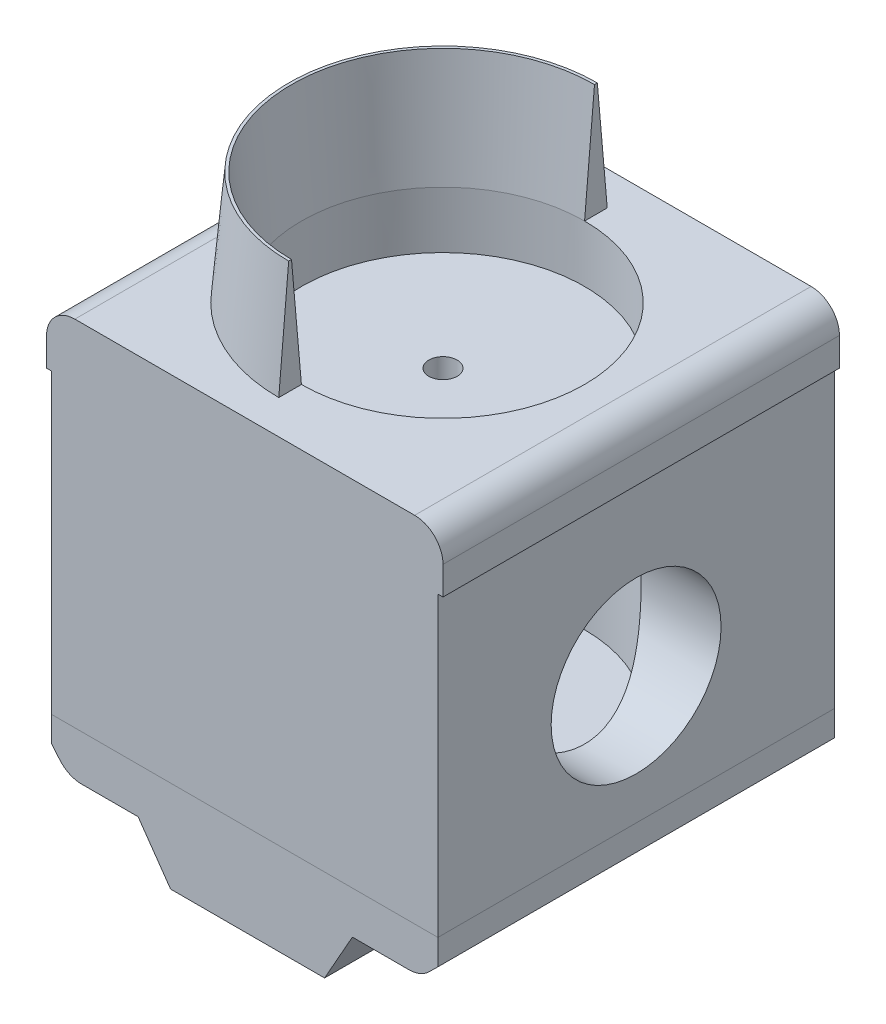
from build123d import *

# Parameters (mm, degrees)
BOSS_EXTRUDE1_DEPTH    = 70
SKETCH4_R              = 29
SKETCH4_R_2            = 25
EXTRUDE_THIN1_DEPTH    = 20
EXTRUDE_THIN1_DRAFT    = 5
SKETCH5_W              = 30
SKETCH5_H              = 70
CUT_EXTRUDE1_DEPTH     = 20
SKETCH7_R              = 25
CUT_EXTRUDE2_DEPTH     = 10
CUT_EXTRUDE3_START     = -68.710206
SKETCH8_R              = 2.5
CUT_EXTRUDE3_DEPTH     = 60.512739
SKETCH10_R             = 15
CUT_EXTRUDE4_DEPTH     = 30
SPLIT3_SURFACE_1_BACK  = 140.799
SPLIT3_SURFACE_1_DEPTH = 281.598
SPLIT3_SURFACE_2_BACK  = 140.799
SPLIT3_SURFACE_2_DEPTH = 281.598
SKETCH14_R             = 1.9
CUT_EXTRUDE5_DEPTH     = 20
SKETCH17_R             = 1.9
CUT_EXTRUDE7_DEPTH     = 20
CUT_EXTRUDE8_START     = -52.5
SKETCH19_R             = 25
CUT_EXTRUDE8_DEPTH     = 42.5


with BuildPart() as part:
    # Sketch1 → Boss-Extrude1 (new body)
    with BuildSketch(Plane.XY):
        with BuildLine():
            ThreePointArc((-1.711084805, -46.340962164), (-3.831514412, -45.869071955), (-5.551700031, -44.542473477))
            Line((-5.551700031, -44.542473477), (-6.980687822, -42.828223009))
            Line((-6.980687822, -42.828223009), (-6.980687822, 14.171776991))
            Line((-6.980687822, 14.171776991), (-7.881398643, 14.171776991))
            Line((-7.881398643, 14.171776991), (-7.881398643, 19.171776991))
            ThreePointArc((-7.881398643, 19.171776991), (-6.416932549, 22.707310897), (-2.881398643, 24.171776991))
            Line((-2.881398643, 24.171776991), (57.118601357, 24.171776991))
            ThreePointArc((57.118601357, 24.171776991), (60.654135263, 22.707310897), (62.118601357, 19.171776991))
            Line((62.118601357, 19.171776991), (62.118601357, 14.171776991))
            Line((62.118601357, 14.171776991), (61.217890536, 14.171776991))
            Line((61.217890536, 14.171776991), (61.217890536, -42.828223009))
            Line((61.217890536, -42.828223009), (59.626717013, -44.393096038))
            ThreePointArc((59.626717013, -44.393096038), (58.014921228, -45.45555297), (56.120767742, -45.828223009))
            Line((56.120767742, -45.828223009), (46.120767742, -45.828223009))
            Line((46.120767742, -45.828223009), (41.208302807, -54.538428992))
            Line((41.208302807, -54.538428992), (14.016177857, -54.538428992))
            Line((14.016177857, -54.538428992), (8.288915195, -46.340962164))
            Line((8.288915195, -46.340962164), (-1.711084805, -46.340962164))
        make_face()
    extrude(amount=BOSS_EXTRUDE1_DEPTH)


with BuildPart() as extrude_thin1_tool:
    # Sketch4 → Extrude-Thin1 (with draft: the straight prism first)
    with BuildSketch(Plane(origin=(0, 24.171776991, 0), x_dir=(1, 0, 0), z_dir=(0, 1, 0))):
        with Locations((27.118601357, -35)):
            Circle(SKETCH4_R)
        with Locations((27.118601357, -35)):
            Circle(SKETCH4_R_2, mode=Mode.SUBTRACT)
    extrude(amount=EXTRUDE_THIN1_DEPTH)
    # Extrude-Thin1: the draft: its side faces are tilted about the plane it starts from
    extrude_thin1_sides = [extrude_thin1_tool.faces().sort_by_distance(p)[0] for p in [
        (-1.881398643, 34.171776991, 35),
        (2.118601357, 34.171776991, 35),
    ]]
    draft(extrude_thin1_sides, Plane(origin=(0, 24.171776991, 0), x_dir=(1, 0, 0), z_dir=(0, 1, 0)), EXTRUDE_THIN1_DRAFT)


with BuildPart() as part_1:
    add(part.part)

    # Extrude-Thin1: add extrude_thin1_tool
    add(extrude_thin1_tool.part)

    # Sketch5 → Cut-Extrude1 (cut)
    with BuildSketch(Plane(origin=(0, 44.171776991, 0), x_dir=(1, 0, 0), z_dir=(0, 1, 0))):
        with Locations((42.118601357, -35)):
            Rectangle(SKETCH5_W, SKETCH5_H)
    extrude(amount=-CUT_EXTRUDE1_DEPTH, mode=Mode.SUBTRACT)

    # Sketch7 → Cut-Extrude2 (cut)
    with BuildSketch(Plane(origin=(0, 24.171776991, 0), x_dir=(1, 0, 0), z_dir=(0, 1, 0))):
        with Locations(Location((27.118601357, -35, 0), (0, 0, 270))):
            Circle(SKETCH7_R)
    extrude(amount=-CUT_EXTRUDE2_DEPTH, mode=Mode.SUBTRACT)

    # Sketch8 → Cut-Extrude3 (cut)
    with BuildSketch(Plane.XZ.offset(54.538428992).offset(CUT_EXTRUDE3_START)):
        with Locations(Location((27.118601357, 35, 0), (0, 0, 90))):
            Circle(SKETCH8_R)
    extrude(amount=CUT_EXTRUDE3_DEPTH, mode=Mode.SUBTRACT)

    # Sketch10 → Cut-Extrude4 (cut)
    with BuildSketch(Plane(origin=(61.217890536, 0, 0), x_dir=(0, 0, -1), z_dir=(1, 0, 0))):
        with Locations((-35, -15.828223009)):
            Circle(SKETCH10_R)
    extrude(amount=-CUT_EXTRUDE4_DEPTH, mode=Mode.SUBTRACT)


with BuildPart() as body_2:
    # Split3: the piece behind the surface
    add(part_1.part)
    # Split3 surface: a surface, the sketch's curves swept straight by 281.598 mm
    with BuildLine(Plane(origin=(0, 0, 0), x_dir=(-1, 0, 0), z_dir=(0, 0, -1)).offset(-SPLIT3_SURFACE_1_BACK), mode=Mode.PRIVATE) as split3_surface_1_path:
        Line((-61.217890536, -38.328223009), (6.980687822, -38.328223009))
    split3_surface_1 = Shell.extrude(split3_surface_1_path.wire(), (0 * SPLIT3_SURFACE_1_DEPTH, 0 * SPLIT3_SURFACE_1_DEPTH, -1 * SPLIT3_SURFACE_1_DEPTH))
    split(bisect_by=split3_surface_1, keep=Keep.BOTTOM)


with BuildPart() as part_2:
    add(part_1.part)

    # Split3: split by a surface, the side it looks to stays
    # Split3 surface: a surface, the sketch's curves swept straight by 281.598 mm
    with BuildLine(Plane(origin=(0, 0, 0), x_dir=(-1, 0, 0), z_dir=(0, 0, -1)).offset(-SPLIT3_SURFACE_2_BACK), mode=Mode.PRIVATE) as split3_surface_2_path:
        Line((-61.217890536, -38.328223009), (6.980687822, -38.328223009))
    split3_surface_2 = Shell.extrude(split3_surface_2_path.wire(), (0 * SPLIT3_SURFACE_2_DEPTH, 0 * SPLIT3_SURFACE_2_DEPTH, -1 * SPLIT3_SURFACE_2_DEPTH))
    split(bisect_by=split3_surface_2, keep=Keep.TOP)


with BuildPart() as cut_extrude5_tool:
    # Sketch14 → Cut-Extrude5 (new body)
    with BuildSketch(Plane.XZ.offset(45.828223009)):
        with Locations(Location((51.120767742, 60, 0), (0, 0, 270))):
            Circle(SKETCH14_R)
        with Locations(Location((51.120767742, 10, 0), (0, 0, 270))):
            Circle(SKETCH14_R)
        with Locations(Location((3.288915195, 60, 0), (0, 0, 270))):
            Circle(SKETCH14_R)
        with Locations(Location((3.288915195, 10, 0), (0, 0, 270))):
            Circle(SKETCH14_R)
    extrude(amount=-CUT_EXTRUDE5_DEPTH)


with BuildPart() as part_3:
    add(part_2.part)

    # Cut-Extrude5: cut by cut_extrude5_tool
    add(cut_extrude5_tool.part, mode=Mode.SUBTRACT)

    # Sketch19 → Cut-Extrude8 (cut)
    with BuildSketch(Plane(origin=(0, 14.171776991, 0), x_dir=(1, 0, 0), z_dir=(0, 1, 0)).offset(CUT_EXTRUDE8_START)):
        with Locations(Location((27.118601357, -35, 0), (0, 0, 270))):
            Circle(SKETCH19_R)
    extrude(amount=CUT_EXTRUDE8_DEPTH, mode=Mode.SUBTRACT)


with BuildPart() as body_2_1:
    add(body_2.part)

    # Cut-Extrude5: cut by cut_extrude5_tool
    add(cut_extrude5_tool.part, mode=Mode.SUBTRACT)

    # Sketch17 → Cut-Extrude7 (cut)
    with BuildSketch(Plane.XZ.offset(46.340962164)):
        with Locations(Location((3.288915195, 60, 0), (0, 0, 270))):
            Circle(SKETCH17_R)
        with Locations(Location((3.288915195, 10, 0), (0, 0, 270))):
            Circle(SKETCH17_R)
    extrude(amount=-CUT_EXTRUDE7_DEPTH, mode=Mode.SUBTRACT)


solid = Compound([part_3.part, body_2_1.part])
